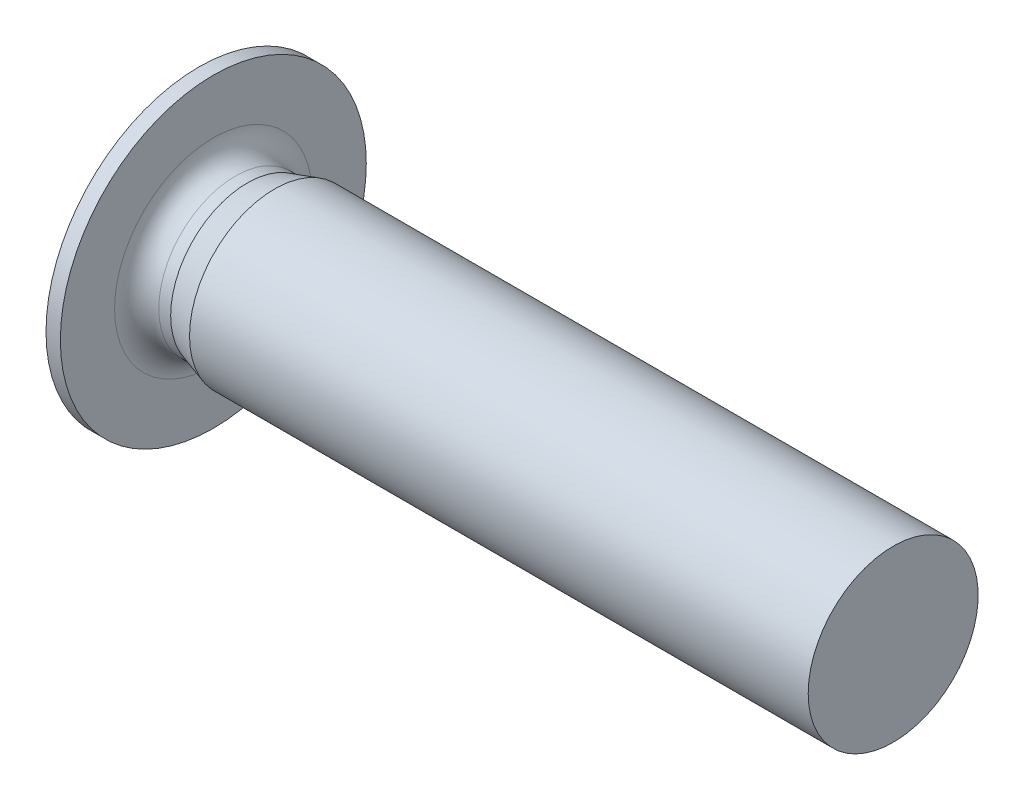
from build123d import *

# Parameters (mm, degrees)
CUT_EXTRUDE1_DEPTH = 1.6
FILLET1_R          = 0.65


with BuildPart() as part:
    # Sketch1 → Revolve1 (revolve)
    with BuildSketch(Plane.XY):
        Polygon((-1, 0), (20, 0), (20, 2.5), (1.8, 2.5), (1, 2.255), (0, 2.255), (0, 4.5), (-0.422649731, 4.5), (-1, 3.5), align=None)
    revolve(axis=Axis((-1, 0, 0), (1, 0, 0)))

    # Sketch2 → Cut-Extrude1 (cut)
    with BuildSketch(Plane.ZY.offset(1)):
        Polygon((-1.443375673, 0), (-0.721687836, -1.25), (0.721687836, -1.25), (1.443375673, 0), (0.721687836, 1.25), (-0.721687836, 1.25), align=None)
    extrude(amount=-CUT_EXTRUDE1_DEPTH, mode=Mode.SUBTRACT)

    # Sketch3 → Cut-Revolve1 (revolve, cut)
    with BuildSketch(Plane.XY):
        Polygon((0.6, -1.25), (0.6, 0), (1.351075774, 0), align=None)
    revolve(axis=Axis((0, 0, 0), (-1, 0, 0)), mode=Mode.SUBTRACT)

    # Fillet1
    fillet1_edges = [part.edges().sort_by_distance(p)[0] for p in [
        (0, -2.255, 0),
    ]]
    fillet(fillet1_edges, radius=FILLET1_R)


solid = part.part
